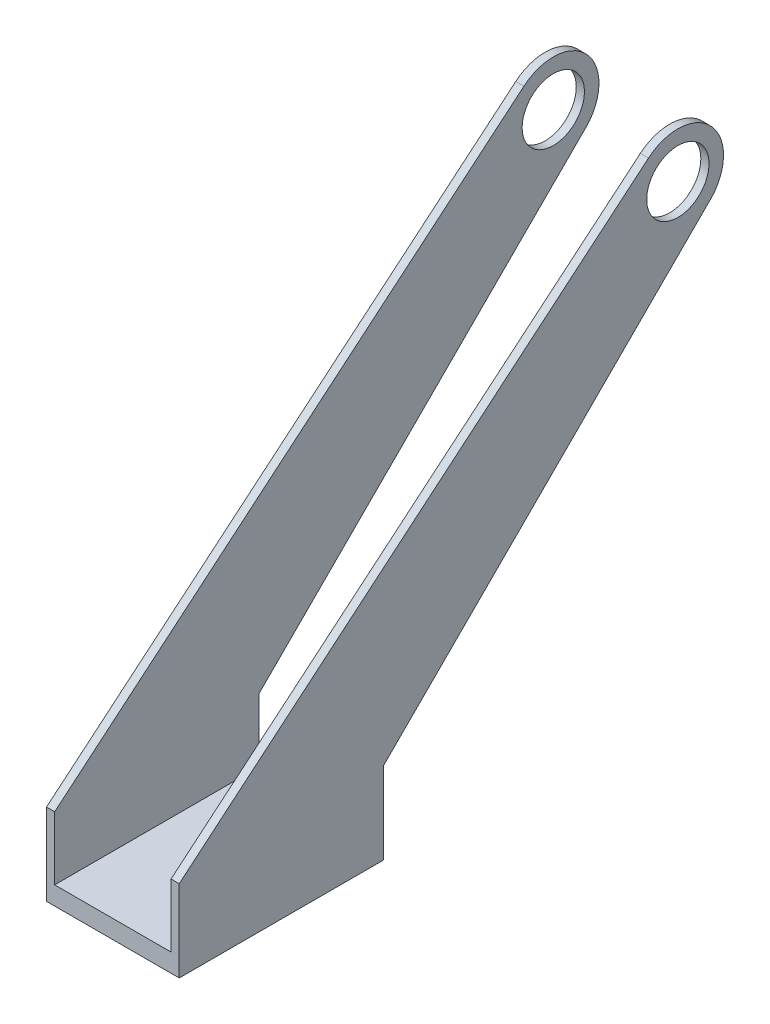
from build123d import *

# Parameters (mm, degrees)
CROQUIS1_R              = 15.25
SALIENTE_EXTRUIR2_DEPTH = 70
CROQUIS3_W              = 57
CROQUIS3_H              = 229.06918818
CORTAR_EXTRUIR1_DEPTH   = 352.435861424
CROQUIS5_R              = 10.7
SALIENTE_EXTRUIR3_DEPTH = 15
CROQUIS1_2_R            = 15.25
CORTAR_EXTRUIR2_DEPTH   = 2.5
CORTAR_EXTRUIR3_START   = -2.5
CROQUIS7_R              = 15.25
CORTAR_EXTRUIR3_DEPTH   = 2.5


with BuildPart() as part:
    # Croquis1 → Saliente-Extruir2 (new body)
    with BuildSketch(Plane(origin=(0, 0, 0), x_dir=(0, 0, -1), z_dir=(1, 0, 0))):
        with BuildLine():
            Line((50.000039636, 19.999952763), (205.563531497, 175.563444624))
            Line((205.563531497, 175.563444624), (208.567950725, 178.567863852))
            ThreePointArc((208.567950725, 178.567863852), (211.324847557, 210.079338837), (179.813372572, 212.836235669))
            Line((179.813372572, 212.836235669), (-49.999960364, 19.999952763))
            Line((-49.999960364, 19.999952763), (-49.999960364, -20.000047237))
            Line((-49.999960364, -20.000047237), (50.000039636, -20.000047237))
            Line((50.000039636, -20.000047237), (50.000039636, 19.999952763))
        make_face()
        with Locations((194.190661648, 195.702049761)):
            Circle(CROQUIS1_R, mode=Mode.SUBTRACT)
    extrude(amount=SALIENTE_EXTRUIR2_DEPTH)

    # Croquis3 → Cortar-Extruir1 (cut, through all)
    with BuildSketch(Plane.XY.offset(49.999960364)):
        with Locations((35, 103.534546853)):
            Rectangle(CROQUIS3_W, CROQUIS3_H)
    extrude(amount=-CORTAR_EXTRUIR1_DEPTH, mode=Mode.SUBTRACT)

    # Croquis5 → Saliente-Extruir3 (add)
    with BuildSketch(Plane.XZ.offset(20.000047237)):
        with Locations((35, -3.9636e-05)):
            Circle(CROQUIS5_R)
    extrude(amount=SALIENTE_EXTRUIR3_DEPTH)

    # Croquis1_2 → Cortar-Extruir2 (cut)
    with BuildSketch(Plane(origin=(0, 0, 0), x_dir=(0, 0, -1), z_dir=(1, 0, 0))):
        with BuildLine():
            Line((50.000039636, 19.999952763), (205.563531497, 175.563444624))
            Line((205.563531497, 175.563444624), (208.567950725, 178.567863852))
            ThreePointArc((208.567950725, 178.567863852), (211.324847557, 210.079338837), (179.813372572, 212.836235669))
            Line((179.813372572, 212.836235669), (-49.999960364, 19.999952763))
            Line((-49.999960364, 19.999952763), (-49.999960364, -20.000047237))
            Line((-49.999960364, -20.000047237), (50.000039636, -20.000047237))
            Line((50.000039636, -20.000047237), (50.000039636, 19.999952763))
        make_face()
        with Locations((194.190661648, 195.702049761)):
            Circle(CROQUIS1_2_R, mode=Mode.SUBTRACT)
    extrude(amount=CORTAR_EXTRUIR2_DEPTH, mode=Mode.SUBTRACT)

    # Croquis7 → Cortar-Extruir3 (cut)
    with BuildSketch(Plane(origin=(70, 0, 0), x_dir=(0, 0, -1), z_dir=(1, 0, 0)).offset(CORTAR_EXTRUIR3_START)):
        with BuildLine():
            Line((179.813372572, 212.836235669), (-49.999960364, 19.999952763))
            Line((-49.999960364, 19.999952763), (-49.999960364, -20.000047237))
            Line((-49.999960364, -20.000047237), (50.000039636, -20.000047237))
            Line((50.000039636, -20.000047237), (50.000039636, 19.999952763))
            Line((50.000039636, 19.999952763), (208.567950725, 178.567863852))
            ThreePointArc((208.567950725, 178.567863852), (211.324847557, 210.079338837), (179.813372572, 212.836235669))
        make_face()
        with Locations((194.190661648, 195.702049761)):
            Circle(CROQUIS7_R, mode=Mode.SUBTRACT)
    extrude(amount=CORTAR_EXTRUIR3_DEPTH, mode=Mode.SUBTRACT)


solid = part.part
